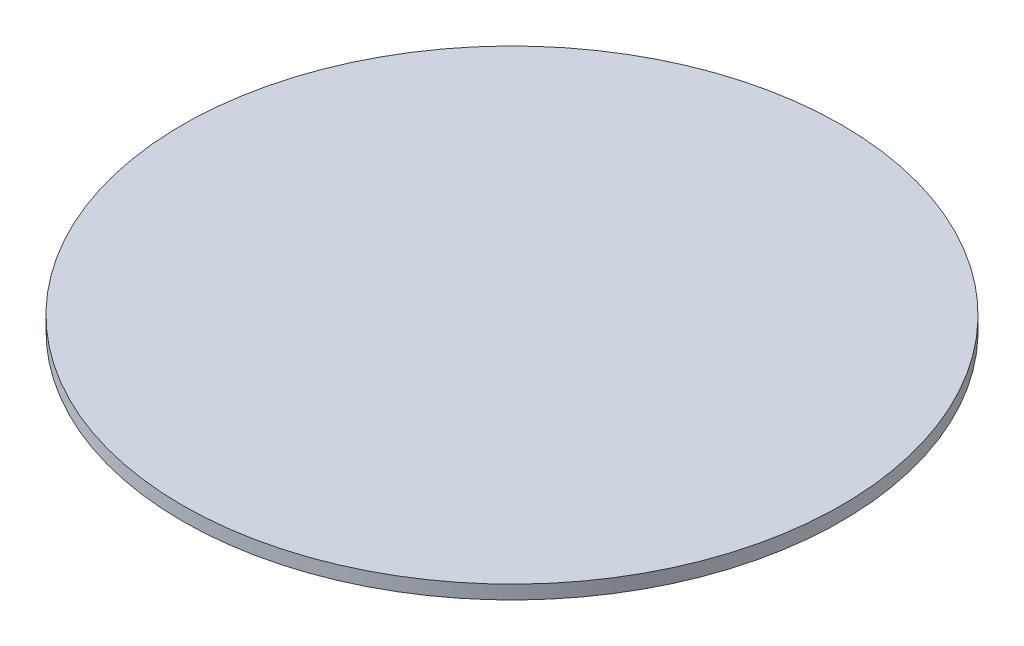
from build123d import *

# Parameters (mm, degrees)
RECORD_SKETCH_R = 76.2
RECORD_DEPTH    = 3.175


with BuildPart() as part:
    # Record Sketch → Record (new body)
    with BuildSketch(Plane(origin=(0, 0, 0), x_dir=(1, 0, 0), z_dir=(0, 1, 0))):
        Circle(RECORD_SKETCH_R)
    extrude(amount=RECORD_DEPTH)


solid = part.part
